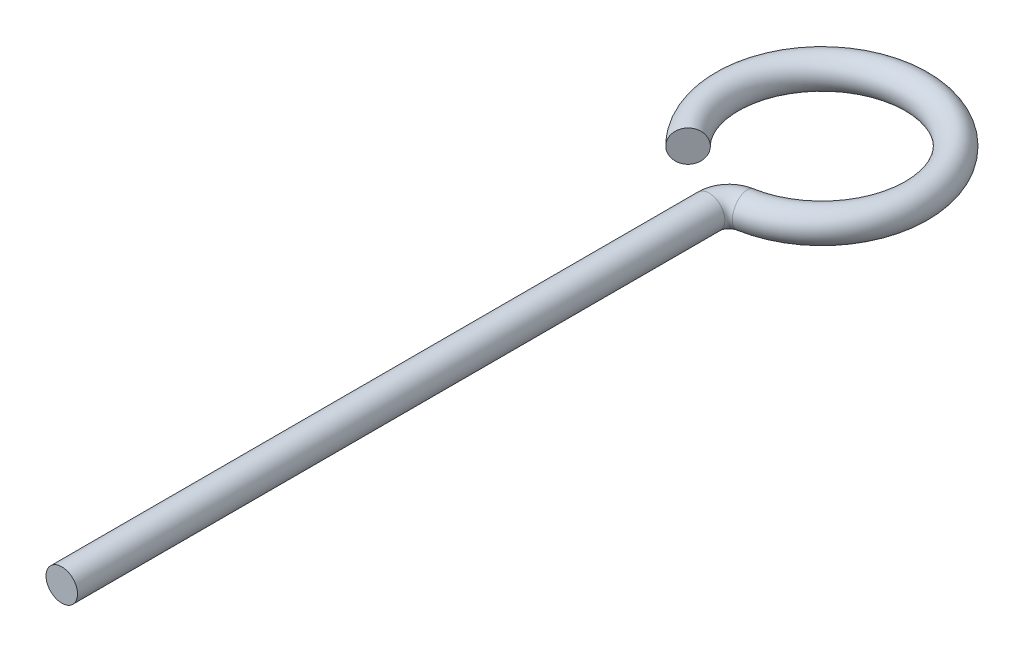
from build123d import *

# Parameters (mm, degrees)
ESBO_O2_R = 1.585


with BuildPart() as part:
    # Varredura1: sweep along a path in Esboço1
    with BuildLine(Plane(origin=(0, 0, 0), x_dir=(1, 0, 0), z_dir=(0, 1, 0))) as varredura1_path:
        Line((0, 0), (0, 65.055093737))
        ThreePointArc((0, 65.055093737), (0.467836858, 66.340580457), (1.652476108, 67.024669108))
        ThreePointArc((1.652476108, 67.024669108), (2.859188253, 85.46001337), (-6.724585489, 69.665414511))
    # Esboço2 → Varredura1 (sweep)
    with BuildSketch(Plane.XY):
        Circle(ESBO_O2_R)
    sweep(path=varredura1_path.line)


solid = part.part
